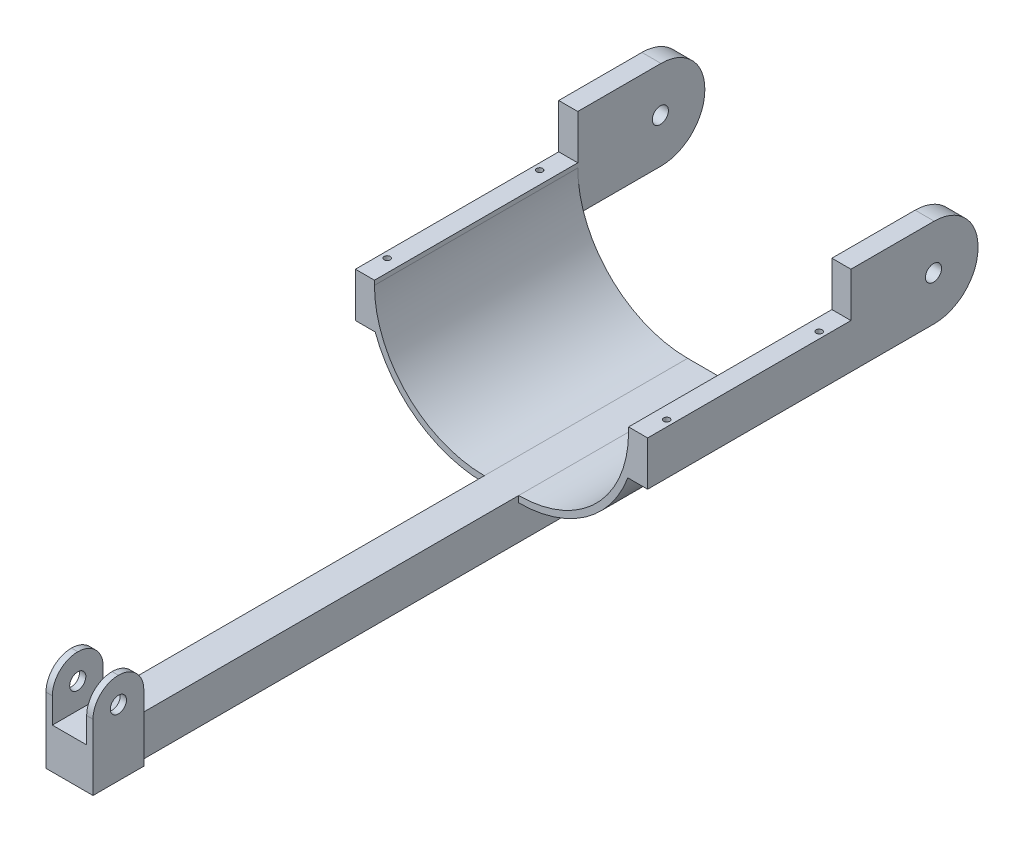
from build123d import *
from build123d.topology import SkipClean

# Parameters (mm, degrees)
BOSS_EXTRUDE1_DEPTH  = 160
SKETCH2_R            = 2.38125
CUT_EXTRUDE1_DEPTH   = 160
SKETCH3_W            = 27
SKETCH3_H            = 500
BOSS_EXTRUDE2_DEPTH  = 27
SKETCH4_W            = 27
SKETCH4_H            = 340
BOSS_EXTRUDE3_DEPTH  = 5
SKETCH5_W            = 40
SKETCH5_H            = 32
BOSS_EXTRUDE4_DEPTH  = 5
BOSS_EXTRUDE5_START  = 5
SKETCH6_W            = 40
SKETCH6_H            = 32
SKETCH6_R            = 6.35
BOSS_EXTRUDE5_DEPTH  = 5
SKETCH7_W            = 10.012295908
SKETCH7_H            = 30
SKETCH7_H_2          = 5
BOSS_EXTRUDE6_DEPTH  = 100
BOSS_EXTRUDE7_START  = -160
SKETCH8_W            = 10.012295908
SKETCH8_H            = 30
BOSS_EXTRUDE7_DEPTH  = 160
CUT_EXTRUDE2_DEPTH   = 100
BOSS_EXTRUDE8_START  = -10.012296
SKETCH10_R           = 6.35
BOSS_EXTRUDE8_DEPTH  = 10.012296
BOSS_EXTRUDE9_START  = -160
SKETCH11_W           = 10.012295908
SKETCH11_H           = 30
BOSS_EXTRUDE9_DEPTH  = 160
SKETCH12_R           = 6.35
BOSS_EXTRUDE10_DEPTH = 4.987704
SKETCH13_R           = 6.35
BOSS_EXTRUDE11_DEPTH = 4.987704
CUT_EXTRUDE3_START   = -200
SKETCH14_R           = 2.38125
CUT_EXTRUDE3_DEPTH   = 200


with BuildPart() as part:
    # Sketch1 → Boss-Extrude1 (new body)
    with BuildSketch(Plane.XY):
        with BuildLine():
            Line((113.5, 0), (86.5, 0))
            ThreePointArc((86.5, 0), (25.335263427, 25.335263427), (0, 86.5))
            Line((0, 86.5), (0, 90))
            Line((0, 90), (-15, 90))
            Line((-15, 90), (-15, 85))
            Line((-15, 85), (-4.987704092, 85))
            ThreePointArc((-4.987704092, 85), (22.332251091, 21.271555285), (86.5, -5))
            Line((86.5, -5), (113.5, -5))
            ThreePointArc((113.5, -5), (177.667748909, 21.271555285), (204.987704092, 85))
            Line((204.987704092, 85), (215, 85))
            Line((215, 85), (215, 90))
            Line((215, 90), (200, 90))
            Line((200, 90), (200, 86.5))
            ThreePointArc((200, 86.5), (174.664736573, 25.335263427), (113.5, 0))
        make_face()
    extrude(amount=BOSS_EXTRUDE1_DEPTH)

    # Sketch2 → Cut-Extrude1 (cut)
    with BuildSketch(Plane.XZ.offset(-85)):
        with BuildLine():
            ThreePointArc((-9.993852046, 142.38125), (-12.375102046, 140), (-9.993852046, 137.61875))
            Line((-9.993852046, 137.61875), (-9.993852046, 142.38125))
        make_face()
        with BuildLine():
            Line((-9.993852046, 142.38125), (-9.993852046, 137.61875))
            ThreePointArc((-9.993852046, 137.61875), (-8.310054023, 138.316201977), (-7.612602046, 140))
            ThreePointArc((-7.612602046, 140), (-8.310054023, 141.683798023), (-9.993852046, 142.38125))
        make_face()
        with Locations(Location((-9.993852046, 20, 0), (0, 0, 270))):
            Circle(SKETCH2_R)
        with Locations(Location((209.993852046, 20, 0), (0, 0, 270))):
            Circle(SKETCH2_R)
        with Locations(Location((209.993852046, 140, 0), (0, 0, 270))):
            Circle(SKETCH2_R)
    extrude(amount=-CUT_EXTRUDE1_DEPTH, mode=Mode.SUBTRACT)

    # Sketch3 → Boss-Extrude2 (add)
    with BuildSketch(Plane(origin=(0, -5, 0), x_dir=(-1, 0, 0), z_dir=(0, -1, 0))):
        with Locations((-100, -250)):
            Rectangle(SKETCH3_W, SKETCH3_H)
    extrude(amount=BOSS_EXTRUDE2_DEPTH)

    # Sketch4 → Boss-Extrude3 (add)
    with BuildSketch(Plane(origin=(0, -5, 0), x_dir=(1, 0, 0), z_dir=(0, 1, 0))):
        with Locations((100, -330)):
            Rectangle(SKETCH4_W, SKETCH4_H)
    extrude(amount=BOSS_EXTRUDE3_DEPTH)

    # Sketch5 → Boss-Extrude4 (add)
    with BuildSketch(Plane(origin=(113.5, 0, 0), x_dir=(0, 0, -1), z_dir=(1, 0, 0))):
        with BuildLine():
            Line((-500, 20.01), (-500, 0))
            Line((-500, 0), (-484.490128061, 15.509871939))
            ThreePointArc((-484.490128061, 15.509871939), (-484.490128061, 24.490128061), (-475.509871939, 24.490128061))
            Line((-475.509871939, 24.490128061), (-465.854935444, 34.145064556))
            ThreePointArc((-465.854935444, 34.145064556), (-472.340158187, 38.478351855), (-479.99, 40))
            Line((-479.99, 40), (-480.01, 40))
            ThreePointArc((-480.01, 40), (-494.145064556, 34.145064556), (-500, 20.01))
        make_face()
        with BuildLine():
            Line((-484.490128061, 15.509871939), (-500, 0))
            Line((-500, 0), (-460, 0))
            Line((-460, 0), (-460, 20.01))
            ThreePointArc((-460, 20.01), (-461.521648145, 27.659841813), (-465.854935444, 34.145064556))
            Line((-465.854935444, 34.145064556), (-475.509871939, 24.490128061))
            ThreePointArc((-475.509871939, 24.490128061), (-474.133364969, 22.430039796), (-473.65, 20))
            ThreePointArc((-473.65, 20), (-477.569960204, 14.133364969), (-484.490128061, 15.509871939))
        make_face()
        with Locations((-480, -16)):
            Rectangle(SKETCH5_W, SKETCH5_H)
    extrude(amount=BOSS_EXTRUDE4_DEPTH)

    # Sketch6 → Boss-Extrude5 (add)
    # profile 1 of 2: a face of its own
    with BuildSketch(Plane.ZY.offset(-86.5).offset(BOSS_EXTRUDE5_START)):
        with Locations((480, -16)):
            Rectangle(SKETCH6_W, SKETCH6_H)
    # profile 2 of 2: a face of its own
    with BuildSketch(Plane.ZY.offset(-86.5).offset(BOSS_EXTRUDE5_START)):
        with BuildLine():
            Line((460, 20.01), (460, 0))
            Line((460, 0), (500, 0))
            Line((500, 0), (500, 20.01))
            ThreePointArc((500, 20.01), (494.145064556, 34.145064556), (480.01, 40))
            Line((480.01, 40), (479.99, 40))
            ThreePointArc((479.99, 40), (465.854935444, 34.145064556), (460, 20.01))
        make_face()
        with Locations(Location((480, 20, 0), (0, 0, 90))):
            Circle(SKETCH6_R, mode=Mode.SUBTRACT)
    extrude(amount=-BOSS_EXTRUDE5_DEPTH)

    # Sketch7 → Boss-Extrude6 (add)
    with BuildSketch(Plane(origin=(0, 0, 0), x_dir=(-1, 0, 0), z_dir=(0, 0, -1))):
        with Locations((-209.993852046, 70)):
            Rectangle(SKETCH7_W, SKETCH7_H)
        with Locations((-209.993852046, 92.5)):
            Rectangle(SKETCH7_W, SKETCH7_H_2)
        with Locations((-209.993852046, 87.5)):
            Rectangle(SKETCH7_W, SKETCH7_H_2)
        with Locations((-209.993852046, 110)):
            Rectangle(SKETCH7_W, SKETCH7_H)
    extrude(amount=BOSS_EXTRUDE6_DEPTH)

    # Sketch8 → Boss-Extrude7 (add)
    with BuildSketch(Plane.XY.offset(160).offset(BOSS_EXTRUDE7_START)):
        with BuildLine():
            Line((199.40692638, 55), (204.987704092, 55))
            Line((204.987704092, 55), (204.987704092, 85))
            ThreePointArc((204.987704092, 85), (203.456732544, 69.765715732), (199.40692638, 55))
        make_face()
        with Locations((209.993852046, 70)):
            Rectangle(SKETCH8_W, SKETCH8_H)
    extrude(amount=BOSS_EXTRUDE7_DEPTH)

    # Sketch9 → Cut-Extrude2 (cut)
    with BuildSketch(Plane(origin=(215, 0, 0), x_dir=(0, 0, -1), z_dir=(1, 0, 0))):
        with BuildLine():
            ThreePointArc((71.35, 90), (67.430039796, 95.866635031), (60.509871939, 94.490128061))
            Line((60.509871939, 94.490128061), (69.490128061, 85.509871939))
            ThreePointArc((69.490128061, 85.509871939), (70.866635031, 87.569960204), (71.35, 90))
        make_face()
        with BuildLine():
            Line((69.490128061, 85.509871939), (60.509871939, 94.490128061))
            ThreePointArc((60.509871939, 94.490128061), (60.509871939, 85.509871939), (69.490128061, 85.509871939))
        make_face()
        with BuildLine():
            ThreePointArc((89.895183951, 65.104816049), (78.702578417, 57.626156128), (65.5, 55))
            Line((65.5, 55), (100, 55))
            Line((100, 55), (89.895183951, 65.104816049))
        make_face()
        with BuildLine():
            Line((100, 55), (100, 89.5))
            ThreePointArc((100, 89.5), (97.373843872, 76.297421583), (89.895183951, 65.104816049))
            Line((89.895183951, 65.104816049), (100, 55))
        make_face()
        with BuildLine():
            Line((100, 125), (65.5, 125))
            ThreePointArc((65.5, 125), (89.895183951, 114.895183951), (100, 90.5))
            Line((100, 90.5), (100, 125))
        make_face()
    extrude(amount=-CUT_EXTRUDE2_DEPTH, mode=Mode.SUBTRACT)

    # Sketch10 → Boss-Extrude8 (add)
    with BuildSketch(Plane.ZY.offset(15).offset(BOSS_EXTRUDE8_START)):
        with BuildLine():
            Line((0, 85), (0, 90))
            Line((0, 90), (0, 125))
            Line((0, 125), (-65.5, 125))
            ThreePointArc((-65.5, 125), (-89.895183951, 114.895183951), (-100, 90.5))
            Line((-100, 90.5), (-100, 89.5))
            ThreePointArc((-100, 89.5), (-89.895183951, 65.104816049), (-65.5, 55))
            Line((-65.5, 55), (0, 55))
            Line((0, 55), (0, 85))
        make_face()
        with Locations(Location((-65, 90, 0), (0, 0, 180))):
            Circle(SKETCH10_R, mode=Mode.SUBTRACT)
    extrude(amount=BOSS_EXTRUDE8_DEPTH)

    # Sketch11 → Boss-Extrude9 (add)
    with BuildSketch(Plane.XY.offset(160).offset(BOSS_EXTRUDE9_START)):
        with Locations((-9.993852046, 70)):
            Rectangle(SKETCH11_W, SKETCH11_H)
        with BuildLine():
            Line((-4.987704092, 85), (-4.987704092, 55))
            Line((-4.987704092, 55), (0.59307362, 55))
            ThreePointArc((0.59307362, 55), (-3.456732544, 69.765715732), (-4.987704092, 85))
        make_face()
    extrude(amount=BOSS_EXTRUDE9_DEPTH)

    # Sketch12 → Boss-Extrude10 (add)
    with BuildSketch(Plane(origin=(-4.987704092, 0, 0), x_dir=(0, 0, -1), z_dir=(1, 0, 0))):
        with BuildLine():
            Line((100, 89.5), (100, 90.5))
            ThreePointArc((100, 90.5), (89.895183951, 114.895183951), (65.5, 125))
            Line((65.5, 125), (0, 125))
            Line((0, 125), (0, 90))
            Line((0, 90), (0, 55))
            Line((0, 55), (65.5, 55))
            ThreePointArc((65.5, 55), (89.895183951, 65.104816049), (100, 89.5))
        make_face()
        with Locations((65, 90)):
            Circle(SKETCH12_R, mode=Mode.SUBTRACT)
    extrude(amount=BOSS_EXTRUDE10_DEPTH)

    # Sketch13 → Boss-Extrude11 (add)
    with SkipClean():  # the faces are left unmerged after this step: merging them gives an invalid solid
        with BuildSketch(Plane.ZY.offset(-204.987704092)):
            with BuildLine():
                Line((-100, 90.5), (-100, 89.5))
                ThreePointArc((-100, 89.5), (-89.895183951, 65.104816049), (-65.5, 55))
                Line((-65.5, 55), (0, 55))
                Line((0, 55), (0, 90))
                Line((0, 90), (0, 125))
                Line((0, 125), (-65.5, 125))
                ThreePointArc((-65.5, 125), (-89.895183951, 114.895183951), (-100, 90.5))
            make_face()
            with Locations(Location((-65, 90, 0), (0, 0, 180))):
                Circle(SKETCH13_R, mode=Mode.SUBTRACT)
        extrude(amount=BOSS_EXTRUDE11_DEPTH)

    # Sketch14 → Cut-Extrude3 (cut)
    with SkipClean():  # the faces are left unmerged after this step: merging them gives an invalid solid
        with BuildSketch(Plane(origin=(0, 85, 0), x_dir=(1, 0, 0), z_dir=(0, 1, 0)).offset(CUT_EXTRUDE3_START)):
            with Locations(Location((-9.993852046, -20, 0), (0, 0, 90))):
                Circle(SKETCH14_R)
            with Locations(Location((-9.993852046, -140, 0), (0, 0, 90))):
                Circle(SKETCH14_R)
            with Locations(Location((209.993852046, -140, 0), (0, 0, 270))):
                Circle(SKETCH14_R)
            with Locations(Location((209.993852046, -20, 0), (0, 0, 270))):
                Circle(SKETCH14_R)
        extrude(amount=CUT_EXTRUDE3_DEPTH, mode=Mode.SUBTRACT)


solid = part.part
